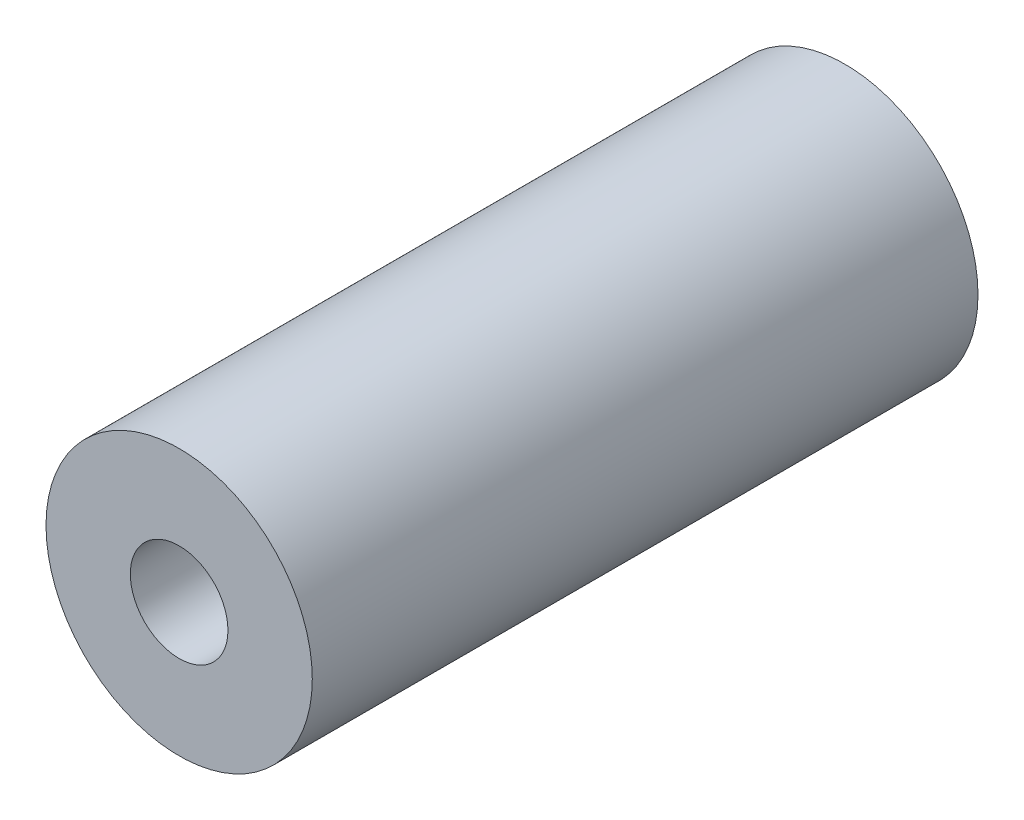
from build123d import *

# Parameters (mm, degrees)
ESQUISSE1_R        = 6
ESQUISSE1_R_2      = 2.2
BOSS_EXTRU_1_DEPTH = 30


with BuildPart() as part:
    # Esquisse1 → Boss.-Extru.1 (new body)
    with BuildSketch(Plane.XY):
        Circle(ESQUISSE1_R)
        Circle(ESQUISSE1_R_2, mode=Mode.SUBTRACT)
    extrude(amount=BOSS_EXTRU_1_DEPTH)


solid = part.part
